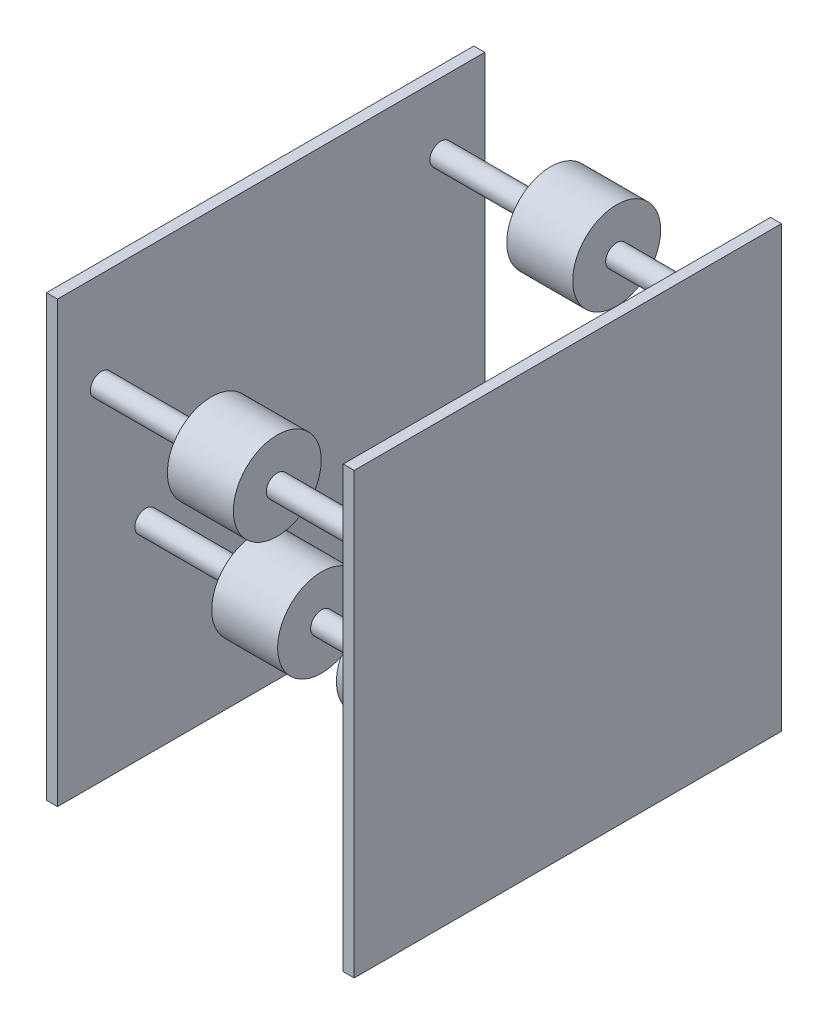
from build123d import *

# Parameters (mm, degrees)
SKETCH1_W               = 246.900926319
SKETCH1_H               = 254
BOSS_EXTRUDE1_DEPTH     = 88.9
SKETCH2_W               = 165.1
SKETCH2_H               = 246.900926319
CUT_EXTRUDE1_DEPTH      = 1
CUT_EXTRUDE1_DEPTH_BACK = 255
SKETCH3_R               = 25.4
BOSS_EXTRUDE2_DEPTH     = 19.05
BOSS_EXTRUDE2_2_DEPTH   = 19.05
BOSS_EXTRUDE2_3_DEPTH   = 19.05
BOSS_EXTRUDE2_4_DEPTH   = 19.05
BOSS_EXTRUDE2_5_DEPTH   = 19.05
BOSS_EXTRUDE3_START     = -82.55
SKETCH4_R               = 6.35
BOSS_EXTRUDE3_DEPTH     = 165.1


with BuildPart() as part:
    # Sketch1 → Boss-Extrude1 (new body, symmetric)
    with BuildSketch(Plane(origin=(0, 0, 0), x_dir=(0, 0, -1), z_dir=(1, 0, 0))):
        with Locations((123.45046316, 127)):
            Rectangle(SKETCH1_W, SKETCH1_H)
    extrude(amount=BOSS_EXTRUDE1_DEPTH, both=True)

    # Sketch2 → Cut-Extrude1 (cut, two sides)
    with BuildSketch(Plane(origin=(0, 254, 0), x_dir=(1, 0, 0), z_dir=(0, 1, 0))) as cut_extrude1_sk:
        with Locations((0, 123.45046316)):
            Rectangle(SKETCH2_W, SKETCH2_H)
    extrude(amount=CUT_EXTRUDE1_DEPTH, mode=Mode.SUBTRACT)
    extrude(cut_extrude1_sk.sketch, amount=-CUT_EXTRUDE1_DEPTH_BACK, mode=Mode.SUBTRACT)



with BuildPart() as body_2:
    # Sketch3 → Boss-Extrude2 (new body, symmetric)
    with BuildSketch(Plane(origin=(0, 0, 0), x_dir=(0, 0, -1), z_dir=(1, 0, 0))):
        with Locations((221.500926319, 215.9)):
            Circle(SKETCH3_R)
    extrude(amount=BOSS_EXTRUDE2_DEPTH, both=True)


with BuildPart() as body_3:
    # Sketch3 → Boss-Extrude2 2 (new body, symmetric)
    with BuildSketch(Plane(origin=(0, 0, 0), x_dir=(0, 0, -1), z_dir=(1, 0, 0))):
        with Locations((25.4, 198.74339204)):
            Circle(SKETCH3_R)
    extrude(amount=BOSS_EXTRUDE2_2_DEPTH, both=True)


with BuildPart() as body_4:
    # Sketch3 → Boss-Extrude2 3 (new body, symmetric)
    with BuildSketch(Plane(origin=(0, 0, 0), x_dir=(0, 0, -1), z_dir=(1, 0, 0))):
        with Locations((221.500926319, 19.05)):
            Circle(SKETCH3_R)
    extrude(amount=BOSS_EXTRUDE2_3_DEPTH, both=True)


with BuildPart() as body_5:
    # Sketch3 → Boss-Extrude2 4 (new body, symmetric)
    with BuildSketch(Plane(origin=(0, 0, 0), x_dir=(0, 0, -1), z_dir=(1, 0, 0))):
        with Locations((123.075926319, 45.422899265)):
            Circle(SKETCH3_R)
    extrude(amount=BOSS_EXTRUDE2_4_DEPTH, both=True)


with BuildPart() as body_6:
    # Sketch3 → Boss-Extrude2 5 (new body, symmetric)
    with BuildSketch(Plane(origin=(0, 0, 0), x_dir=(0, 0, -1), z_dir=(1, 0, 0))):
        with Locations((51.023825584, 117.475)):
            Circle(SKETCH3_R)
    extrude(amount=BOSS_EXTRUDE2_5_DEPTH, both=True)


with BuildPart() as part_1:
    add(part.part)

    add(body_2.part)  # Boss-Extrude3 merges body 2

    add(body_3.part)  # Boss-Extrude3 merges body 3

    add(body_4.part)  # Boss-Extrude3 merges body 4

    add(body_5.part)  # Boss-Extrude3 merges body 5

    add(body_6.part)  # Boss-Extrude3 merges body 6
    # Sketch4 → Boss-Extrude3 (add)
    with BuildSketch(Plane(origin=(0, 0, 0), x_dir=(0, 0, -1), z_dir=(1, 0, 0)).offset(BOSS_EXTRUDE3_START)):
        with Locations((221.500926319, 19.05)):
            Circle(SKETCH4_R)
        with Locations((123.075926319, 45.422899265)):
            Circle(SKETCH4_R)
        with Locations((51.023825584, 117.475)):
            Circle(SKETCH4_R)
        with Locations((25.4, 198.74339204)):
            Circle(SKETCH4_R)
        with Locations((221.500926319, 215.9)):
            Circle(SKETCH4_R)
    extrude(amount=BOSS_EXTRUDE3_DEPTH)


solid = part_1.part
